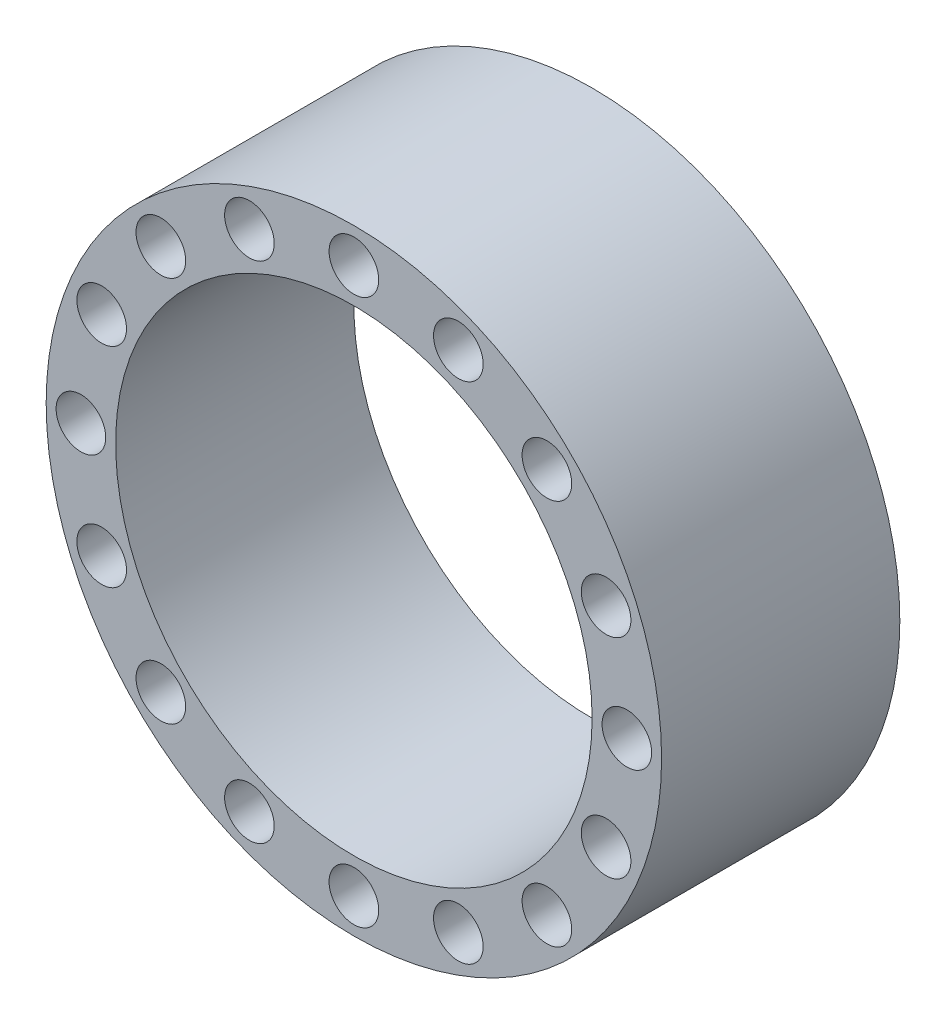
from build123d import *

# Parameters (mm, degrees)
SKETCH_1_R                = 31
SKETCH_1_R_2              = 24
EXTRUDE_1_DEPTH           = 24
HOLE_WIZARD_M3_1_D        = 3.4
SKETCH_7_R                = 2.5
CUT_EXTRUDE_3_DEPTH       = 6
PATTERN_CIRCULAR_3_COUNT  = 16
MIRROR_1_COPY_1_D         = 3.4
MIRROR_1_COPY_2_D         = 3.4
MIRROR_1_COPY_3_D         = 3.4
MIRROR_1_COPY_4_D         = 3.4
MIRROR_1_COPY_5_D         = 3.4
MIRROR_1_COPY_6_D         = 3.4
MIRROR_1_COPY_7_D         = 3.4
MIRROR_1_COPY_8_D         = 3.4
MIRROR_1_COPY_9_D         = 3.4
MIRROR_1_COPY_10_D        = 3.4
MIRROR_1_COPY_11_D        = 3.4
MIRROR_1_COPY_12_D        = 3.4
MIRROR_1_COPY_13_D        = 3.4
MIRROR_1_COPY_14_D        = 3.4
MIRROR_1_COPY_15_D        = 3.4
MIRROR_1_COPY_16_SKETCH_R = 2.5
MIRROR_1_COPY_16_DEPTH    = 6
MIRROR_1_COPY_17_SKETCH_R = 2.5
MIRROR_1_COPY_17_DEPTH    = 6
MIRROR_1_COPY_18_SKETCH_R = 2.5
MIRROR_1_COPY_18_DEPTH    = 6
MIRROR_1_COPY_19_SKETCH_R = 2.5
MIRROR_1_COPY_19_DEPTH    = 6
MIRROR_1_COPY_20_SKETCH_R = 2.5
MIRROR_1_COPY_20_DEPTH    = 6
MIRROR_1_COPY_21_SKETCH_R = 2.5
MIRROR_1_COPY_21_DEPTH    = 6
MIRROR_1_COPY_22_SKETCH_R = 2.5
MIRROR_1_COPY_22_DEPTH    = 6
MIRROR_1_COPY_23_SKETCH_R = 2.5
MIRROR_1_COPY_23_DEPTH    = 6
MIRROR_1_COPY_24_SKETCH_R = 2.5
MIRROR_1_COPY_24_DEPTH    = 6
MIRROR_1_COPY_25_SKETCH_R = 2.5
MIRROR_1_COPY_25_DEPTH    = 6
MIRROR_1_COPY_26_SKETCH_R = 2.5
MIRROR_1_COPY_26_DEPTH    = 6
MIRROR_1_COPY_27_SKETCH_R = 2.5
MIRROR_1_COPY_27_DEPTH    = 6
MIRROR_1_COPY_28_SKETCH_R = 2.5
MIRROR_1_COPY_28_DEPTH    = 6
MIRROR_1_COPY_29_SKETCH_R = 2.5
MIRROR_1_COPY_29_DEPTH    = 6
MIRROR_1_COPY_30_SKETCH_R = 2.5
MIRROR_1_COPY_30_DEPTH    = 6
MIRROR_1_COPY_31_D        = 3.4


with BuildPart() as part:
    # ｽｹｯﾁ1 → ﾎﾞｽ - 押し出し1 (new body)
    with BuildSketch(Plane.XY):
        Circle(SKETCH_1_R)
        Circle(SKETCH_1_R_2, mode=Mode.SUBTRACT)
    extrude(amount=EXTRUDE_1_DEPTH)

    # M3 すきま穴1 (through all)
    with Locations(Plane.XY.offset(24)):
        with Locations((0, 27.5)):
            hole_wizard_m3_1 = Hole(HOLE_WIZARD_M3_1_D / 2)

    # ｽｹｯﾁ7 → ｶｯﾄ - 押し出し3 (cut)
    with BuildSketch(Plane.XY.offset(24)):
        with Locations((0, 27.5)):
            Circle(SKETCH_7_R)
    cut_extrude_3 = extrude(amount=-CUT_EXTRUDE_3_DEPTH, mode=Mode.SUBTRACT)

    # 円形ﾊﾟﾀｰﾝ3: M3 すきま穴1, ｶｯﾄ - 押し出し3 ×16 about axis
    pattern_circular_3_axis = Axis((0, 0, 0), (0, 0, 1))
    for i in range(1, PATTERN_CIRCULAR_3_COUNT):
        add(hole_wizard_m3_1.rotate(pattern_circular_3_axis, i * 360 / PATTERN_CIRCULAR_3_COUNT), mode=Mode.SUBTRACT)
        add(cut_extrude_3.rotate(pattern_circular_3_axis, i * 360 / PATTERN_CIRCULAR_3_COUNT), mode=Mode.SUBTRACT)

    # ﾐﾗｰ1: ｶｯﾄ - 押し出し3 across plane
    add(cut_extrude_3.mirror(Plane(origin=(0, 0, 12), x_dir=(1, 0, 0), z_dir=(0, 0, -1))), mode=Mode.SUBTRACT)

    # ﾐﾗｰ1 copy 1 (through all)
    with Locations(Plane(origin=(0, 0, 0), x_dir=(0.923879533, 0.382683432, 0), z_dir=(0, 0, -1))):
        with Locations((0, -27.5)):
            Hole(MIRROR_1_COPY_1_D / 2)

    # ﾐﾗｰ1 copy 2 (through all)
    with Locations(Plane(origin=(0, 0, 0), x_dir=(0.707106781, 0.707106781, 0), z_dir=(0, 0, -1))):
        with Locations((0, -27.5)):
            Hole(MIRROR_1_COPY_2_D / 2)

    # ﾐﾗｰ1 copy 3 (through all)
    with Locations(Plane(origin=(0, 0, 0), x_dir=(0.382683432, 0.923879533, 0), z_dir=(0, 0, -1))):
        with Locations((0, -27.5)):
            Hole(MIRROR_1_COPY_3_D / 2)

    # ﾐﾗｰ1 copy 4 (through all)
    with Locations(Plane.YX):
        with Locations((0, -27.5)):
            Hole(MIRROR_1_COPY_4_D / 2)

    # ﾐﾗｰ1 copy 5 (through all)
    with Locations(Plane(origin=(0, 0, 0), x_dir=(-0.382683432, 0.923879533, 0), z_dir=(0, 0, -1))):
        with Locations((0, -27.5)):
            Hole(MIRROR_1_COPY_5_D / 2)

    # ﾐﾗｰ1 copy 6 (through all)
    with Locations(Plane(origin=(0, 0, 0), x_dir=(-0.707106781, 0.707106781, 0), z_dir=(0, 0, -1))):
        with Locations((0, -27.5)):
            Hole(MIRROR_1_COPY_6_D / 2)

    # ﾐﾗｰ1 copy 7 (through all)
    with Locations(Plane(origin=(0, 0, 0), x_dir=(-0.923879533, 0.382683432, 0), z_dir=(0, 0, -1))):
        with Locations((0, -27.5)):
            Hole(MIRROR_1_COPY_7_D / 2)

    # ﾐﾗｰ1 copy 8 (through all)
    with Locations(Plane(origin=(0, 0, 0), x_dir=(-1, 0, 0), z_dir=(0, 0, -1))):
        with Locations((0, -27.5)):
            Hole(MIRROR_1_COPY_8_D / 2)

    # ﾐﾗｰ1 copy 9 (through all)
    with Locations(Plane(origin=(0, 0, 0), x_dir=(-0.923879533, -0.382683432, 0), z_dir=(0, 0, -1))):
        with Locations((0, -27.5)):
            Hole(MIRROR_1_COPY_9_D / 2)

    # ﾐﾗｰ1 copy 10 (through all)
    with Locations(Plane(origin=(0, 0, 0), x_dir=(-0.707106781, -0.707106781, 0), z_dir=(0, 0, -1))):
        with Locations((0, -27.5)):
            Hole(MIRROR_1_COPY_10_D / 2)

    # ﾐﾗｰ1 copy 11 (through all)
    with Locations(Plane(origin=(0, 0, 0), x_dir=(-0.382683432, -0.923879533, 0), z_dir=(0, 0, -1))):
        with Locations((0, -27.5)):
            Hole(MIRROR_1_COPY_11_D / 2)

    # ﾐﾗｰ1 copy 12 (through all)
    with Locations(Plane(origin=(0, 0, 0), x_dir=(0, -1, 0), z_dir=(0, 0, -1))):
        with Locations((0, -27.5)):
            Hole(MIRROR_1_COPY_12_D / 2)

    # ﾐﾗｰ1 copy 13 (through all)
    with Locations(Plane(origin=(0, 0, 0), x_dir=(0.382683432, -0.923879533, 0), z_dir=(0, 0, -1))):
        with Locations((0, -27.5)):
            Hole(MIRROR_1_COPY_13_D / 2)

    # ﾐﾗｰ1 copy 14 (through all)
    with Locations(Plane(origin=(0, 0, 0), x_dir=(0.707106781, -0.707106781, 0), z_dir=(0, 0, -1))):
        with Locations((0, -27.5)):
            Hole(MIRROR_1_COPY_14_D / 2)

    # ﾐﾗｰ1 copy 15 (through all)
    with Locations(Plane(origin=(0, 0, 0), x_dir=(0.923879533, -0.382683432, 0), z_dir=(0, 0, -1))):
        with Locations((0, -27.5)):
            Hole(MIRROR_1_COPY_15_D / 2)

    # ﾐﾗｰ1 copy 16 sketch → ﾐﾗｰ1 copy 16 (cut)
    with BuildSketch(Plane(origin=(0, 0, 0), x_dir=(0.923879533, 0.382683432, 0), z_dir=(0, 0, -1))):
        with Locations((0, -27.5)):
            Circle(MIRROR_1_COPY_16_SKETCH_R)
    extrude(amount=-MIRROR_1_COPY_16_DEPTH, mode=Mode.SUBTRACT)

    # ﾐﾗｰ1 copy 17 sketch → ﾐﾗｰ1 copy 17 (cut)
    with BuildSketch(Plane(origin=(0, 0, 0), x_dir=(0.707106781, 0.707106781, 0), z_dir=(0, 0, -1))):
        with Locations((0, -27.5)):
            Circle(MIRROR_1_COPY_17_SKETCH_R)
    extrude(amount=-MIRROR_1_COPY_17_DEPTH, mode=Mode.SUBTRACT)

    # ﾐﾗｰ1 copy 18 sketch → ﾐﾗｰ1 copy 18 (cut)
    with BuildSketch(Plane(origin=(0, 0, 0), x_dir=(0.382683432, 0.923879533, 0), z_dir=(0, 0, -1))):
        with Locations((0, -27.5)):
            Circle(MIRROR_1_COPY_18_SKETCH_R)
    extrude(amount=-MIRROR_1_COPY_18_DEPTH, mode=Mode.SUBTRACT)

    # ﾐﾗｰ1 copy 19 sketch → ﾐﾗｰ1 copy 19 (cut)
    with BuildSketch(Plane.YX):
        with Locations((0, -27.5)):
            Circle(MIRROR_1_COPY_19_SKETCH_R)
    extrude(amount=-MIRROR_1_COPY_19_DEPTH, mode=Mode.SUBTRACT)

    # ﾐﾗｰ1 copy 20 sketch → ﾐﾗｰ1 copy 20 (cut)
    with BuildSketch(Plane(origin=(0, 0, 0), x_dir=(-0.382683432, 0.923879533, 0), z_dir=(0, 0, -1))):
        with Locations((0, -27.5)):
            Circle(MIRROR_1_COPY_20_SKETCH_R)
    extrude(amount=-MIRROR_1_COPY_20_DEPTH, mode=Mode.SUBTRACT)

    # ﾐﾗｰ1 copy 21 sketch → ﾐﾗｰ1 copy 21 (cut)
    with BuildSketch(Plane(origin=(0, 0, 0), x_dir=(-0.707106781, 0.707106781, 0), z_dir=(0, 0, -1))):
        with Locations((0, -27.5)):
            Circle(MIRROR_1_COPY_21_SKETCH_R)
    extrude(amount=-MIRROR_1_COPY_21_DEPTH, mode=Mode.SUBTRACT)

    # ﾐﾗｰ1 copy 22 sketch → ﾐﾗｰ1 copy 22 (cut)
    with BuildSketch(Plane(origin=(0, 0, 0), x_dir=(-0.923879533, 0.382683432, 0), z_dir=(0, 0, -1))):
        with Locations((0, -27.5)):
            Circle(MIRROR_1_COPY_22_SKETCH_R)
    extrude(amount=-MIRROR_1_COPY_22_DEPTH, mode=Mode.SUBTRACT)

    # ﾐﾗｰ1 copy 23 sketch → ﾐﾗｰ1 copy 23 (cut)
    with BuildSketch(Plane(origin=(0, 0, 0), x_dir=(-1, 0, 0), z_dir=(0, 0, -1))):
        with Locations((0, -27.5)):
            Circle(MIRROR_1_COPY_23_SKETCH_R)
    extrude(amount=-MIRROR_1_COPY_23_DEPTH, mode=Mode.SUBTRACT)

    # ﾐﾗｰ1 copy 24 sketch → ﾐﾗｰ1 copy 24 (cut)
    with BuildSketch(Plane(origin=(0, 0, 0), x_dir=(-0.923879533, -0.382683432, 0), z_dir=(0, 0, -1))):
        with Locations((0, -27.5)):
            Circle(MIRROR_1_COPY_24_SKETCH_R)
    extrude(amount=-MIRROR_1_COPY_24_DEPTH, mode=Mode.SUBTRACT)

    # ﾐﾗｰ1 copy 25 sketch → ﾐﾗｰ1 copy 25 (cut)
    with BuildSketch(Plane(origin=(0, 0, 0), x_dir=(-0.707106781, -0.707106781, 0), z_dir=(0, 0, -1))):
        with Locations((0, -27.5)):
            Circle(MIRROR_1_COPY_25_SKETCH_R)
    extrude(amount=-MIRROR_1_COPY_25_DEPTH, mode=Mode.SUBTRACT)

    # ﾐﾗｰ1 copy 26 sketch → ﾐﾗｰ1 copy 26 (cut)
    with BuildSketch(Plane(origin=(0, 0, 0), x_dir=(-0.382683432, -0.923879533, 0), z_dir=(0, 0, -1))):
        with Locations((0, -27.5)):
            Circle(MIRROR_1_COPY_26_SKETCH_R)
    extrude(amount=-MIRROR_1_COPY_26_DEPTH, mode=Mode.SUBTRACT)

    # ﾐﾗｰ1 copy 27 sketch → ﾐﾗｰ1 copy 27 (cut)
    with BuildSketch(Plane(origin=(0, 0, 0), x_dir=(0, -1, 0), z_dir=(0, 0, -1))):
        with Locations((0, -27.5)):
            Circle(MIRROR_1_COPY_27_SKETCH_R)
    extrude(amount=-MIRROR_1_COPY_27_DEPTH, mode=Mode.SUBTRACT)

    # ﾐﾗｰ1 copy 28 sketch → ﾐﾗｰ1 copy 28 (cut)
    with BuildSketch(Plane(origin=(0, 0, 0), x_dir=(0.382683432, -0.923879533, 0), z_dir=(0, 0, -1))):
        with Locations((0, -27.5)):
            Circle(MIRROR_1_COPY_28_SKETCH_R)
    extrude(amount=-MIRROR_1_COPY_28_DEPTH, mode=Mode.SUBTRACT)

    # ﾐﾗｰ1 copy 29 sketch → ﾐﾗｰ1 copy 29 (cut)
    with BuildSketch(Plane(origin=(0, 0, 0), x_dir=(0.707106781, -0.707106781, 0), z_dir=(0, 0, -1))):
        with Locations((0, -27.5)):
            Circle(MIRROR_1_COPY_29_SKETCH_R)
    extrude(amount=-MIRROR_1_COPY_29_DEPTH, mode=Mode.SUBTRACT)

    # ﾐﾗｰ1 copy 30 sketch → ﾐﾗｰ1 copy 30 (cut)
    with BuildSketch(Plane(origin=(0, 0, 0), x_dir=(0.923879533, -0.382683432, 0), z_dir=(0, 0, -1))):
        with Locations((0, -27.5)):
            Circle(MIRROR_1_COPY_30_SKETCH_R)
    extrude(amount=-MIRROR_1_COPY_30_DEPTH, mode=Mode.SUBTRACT)

    # ﾐﾗｰ1 copy 31 (through all)
    with Locations(Plane(origin=(0, 0, 0), x_dir=(1, 0, 0), z_dir=(0, 0, -1))):
        with Locations((0, -27.5)):
            Hole(MIRROR_1_COPY_31_D / 2)


solid = part.part
